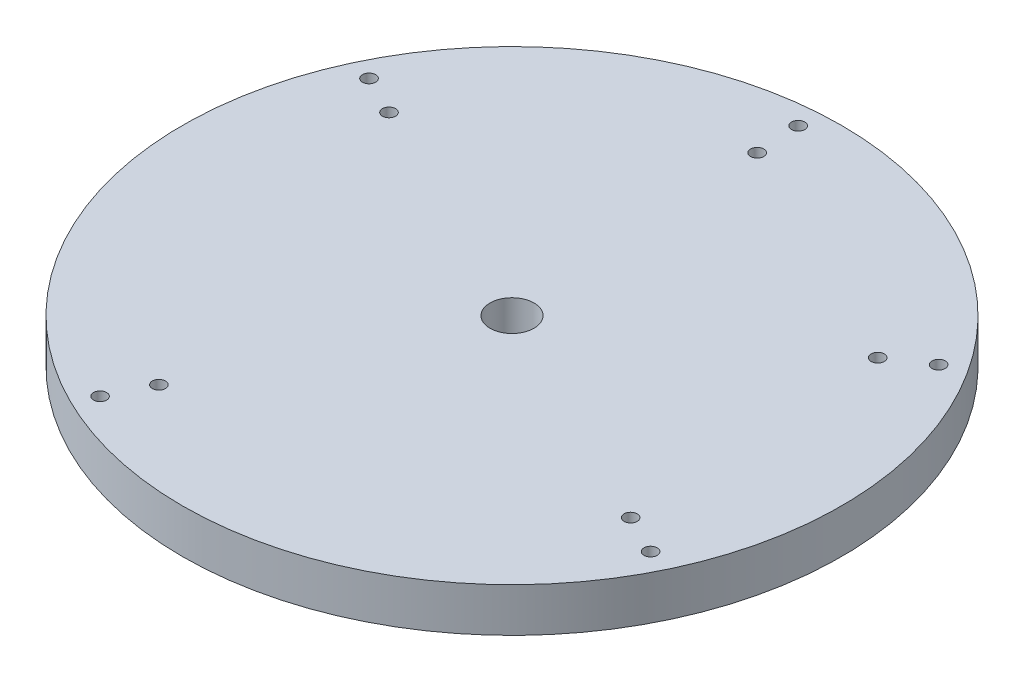
from build123d import *

# Parameters (mm, degrees)
SKETCH1_R               = 75
SKETCH1_R_2             = 5
BOSS_EXTRUDE1_DEPTH     = 10
SKETCH4_R               = 1.5
CUT_EXTRUDE1_DEPTH      = 1
CUT_EXTRUDE1_DEPTH_BACK = 11


with BuildPart() as part:
    # Sketch1 → Boss-Extrude1 (new body)
    with BuildSketch(Plane(origin=(0, 0, 0), x_dir=(1, 0, 0), z_dir=(0, 1, 0))):
        Circle(SKETCH1_R)
        Circle(SKETCH1_R_2, mode=Mode.SUBTRACT)
    extrude(amount=BOSS_EXTRUDE1_DEPTH)

    # Sketch4 → Cut-Extrude1 (cut, two sides)
    with BuildSketch(Plane(origin=(0, 10, 0), x_dir=(1, 0, 0), z_dir=(0, 1, 0))) as cut_extrude1_sk:
        with Locations((-26.550808926, -53.805711085)):
            Circle(SKETCH4_R)
        with Locations((-30.975943747, -62.773329599)):
            Circle(SKETCH4_R)
        with Locations((-63.01509769, 30.480268572)):
            Circle(SKETCH4_R)
        with Locations((-54.047479176, 26.05513375)):
            Circle(SKETCH4_R)
        with Locations((62.277654423, -30.734175657)):
            Circle(SKETCH4_R)
        with Locations((53.310035909, -26.309040836)):
            Circle(SKETCH4_R)
        with Locations((-4.853556436, 69.978752855)):
            Circle(SKETCH4_R)
        with Locations((-4.202026349, 60)):
            Circle(SKETCH4_R)
        with Locations((49.896530564, 33.321708205)):
            Circle(SKETCH4_R)
        with Locations((58.212618991, 38.875326239)):
            Circle(SKETCH4_R)
    extrude(amount=CUT_EXTRUDE1_DEPTH, mode=Mode.SUBTRACT)
    extrude(cut_extrude1_sk.sketch, amount=-CUT_EXTRUDE1_DEPTH_BACK, mode=Mode.SUBTRACT)


solid = part.part
